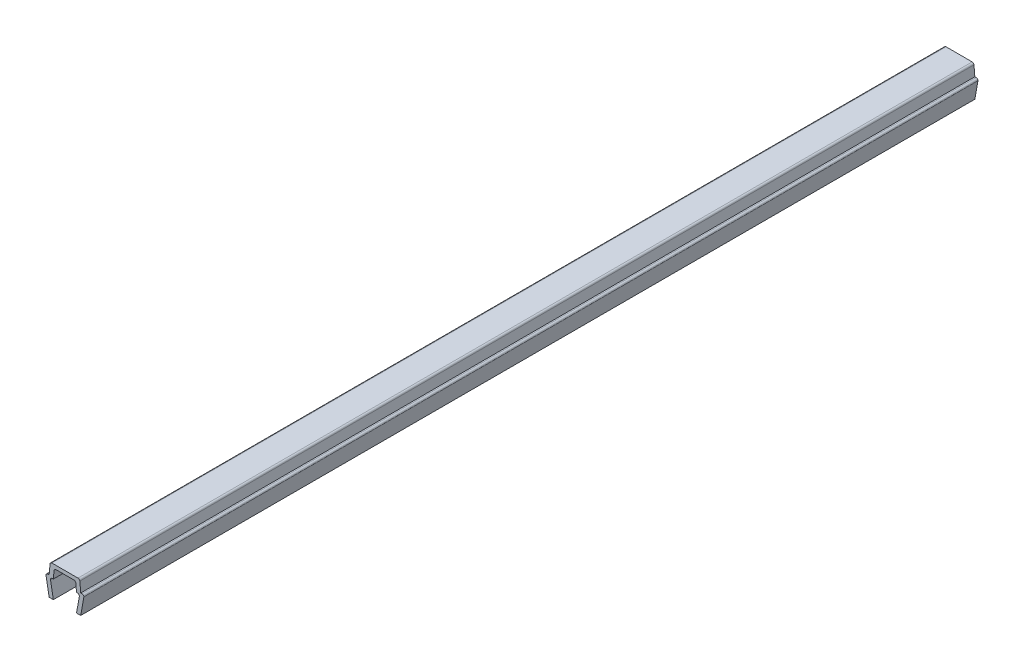
from build123d import *

# Parameters (mm, degrees)
BOSS_EXTRUDE1_DEPTH = 85


with BuildPart() as part:
    # Sketch1 → Boss-Extrude1 (new body, symmetric)
    with BuildSketch(Plane.XY):
        with BuildLine():
            Line((-3.6, 3.35), (-3, 0))
            Line((-3, 0), (-2.2, 0))
            Line((-2.2, 0), (-2.735217071, 2.988295315))
            ThreePointArc((-2.735217071, 2.988295315), (-2.659117427, 3.274614514), (-2.390699246, 3.4))
            Line((-2.390699246, 3.4), (-2.2, 3.4))
            Line((-2.2, 3.4), (-2.070472639, 4.88050451))
            ThreePointArc((-2.070472639, 4.88050451), (-1.958261067, 5.108047068), (-1.721804495, 5.2))
            Line((-1.721804495, 5.2), (1.721804495, 5.2))
            ThreePointArc((1.721804495, 5.2), (1.958261067, 5.108047068), (2.070472639, 4.88050451))
            Line((2.070472639, 4.88050451), (2.2, 3.4))
            Line((2.2, 3.4), (2.390699246, 3.4))
            ThreePointArc((2.390699246, 3.4), (2.659117427, 3.274614514), (2.735217071, 2.988295315))
            Line((2.735217071, 2.988295315), (2.2, 0))
            Line((2.2, 0), (3, 0))
            Line((3, 0), (3.6, 3.35))
            ThreePointArc((3.6, 3.35), (3.497487373, 3.597487373), (3.25, 3.7))
            Line((3.25, 3.7), (3, 3.7))
            Line((3, 3.7), (2.835477174, 5.58050451))
            ThreePointArc((2.835477174, 5.58050451), (2.723265602, 5.808047068), (2.486809029, 5.9))
            Line((2.486809029, 5.9), (-2.486809029, 5.9))
            ThreePointArc((-2.486809029, 5.9), (-2.723265602, 5.808047068), (-2.835477174, 5.58050451))
            Line((-2.835477174, 5.58050451), (-3, 3.7))
            Line((-3, 3.7), (-3.25, 3.7))
            ThreePointArc((-3.25, 3.7), (-3.497487373, 3.597487373), (-3.6, 3.35))
        make_face()
    extrude(amount=BOSS_EXTRUDE1_DEPTH, both=True)


solid = part.part
